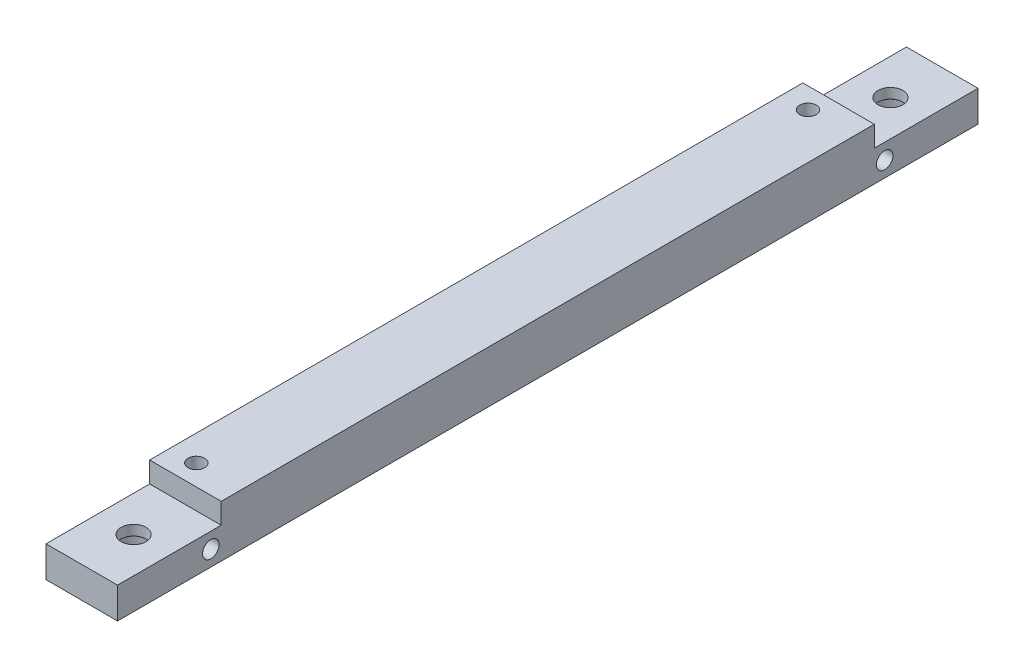
from build123d import *

# Parameters (mm, degrees)
SKETCH1_W                                      = 83
SKETCH1_H                                      = 6
BOSS_EXTRUDE1_DEPTH                            = 8.5
SKETCH7_W                                      = 8.5
SKETCH7_H                                      = 10
CUT_EXTRUDE6_DEPTH                             = 3
SKETCH18_W                                     = 10
SKETCH18_H                                     = 3
CUT_EXTRUDE8_DEPTH                             = 10
SKETCH21_W                                     = 63
SKETCH21_H                                     = 1
CUT_EXTRUDE9_DEPTH                             = 10
M2X0_4_TAPPED_HOLE3_D                          = 1.6
SKETCH27_W                                     = 1.6
SKETCH27_H                                     = 83
CUT_EXTRUDE12_DEPTH                            = 10
CBORE_FOR_M2_SOCKET_HEAD_CAP_SCREW1_AT_2_COUNT = 2
CBORE_FOR_M2_SOCKET_HEAD_CAP_SCREW1_AT_2_PITCH = 73
M2X0_4_TAPPED_HOLE2_D                          = 1.6


with BuildPart() as part:
    # Sketch1 → Boss-Extrude1 (new body)
    with BuildSketch(Plane(origin=(0, 0, 0), x_dir=(0, 0, -1), z_dir=(1, 0, 0))):
        with Locations((41.5, -5.098419508)):
            Rectangle(SKETCH1_W, SKETCH1_H)
    extrude(amount=BOSS_EXTRUDE1_DEPTH)

    # Sketch7 → Cut-Extrude6 (cut)
    with BuildSketch(Plane(origin=(0, -2.098419508, 0), x_dir=(1, 0, 0), z_dir=(0, 1, 0))):
        with Locations((4.25, 5)):
            Rectangle(SKETCH7_W, SKETCH7_H)
    extrude(amount=-CUT_EXTRUDE6_DEPTH, mode=Mode.SUBTRACT)

    # Sketch18 → Cut-Extrude8 (cut)
    with BuildSketch(Plane(origin=(8.5, 0, 0), x_dir=(0, 0, -1), z_dir=(1, 0, 0))):
        with Locations((78, -3.598419508)):
            Rectangle(SKETCH18_W, SKETCH18_H)
    extrude(amount=-CUT_EXTRUDE8_DEPTH, mode=Mode.SUBTRACT)

    # Sketch21 → Cut-Extrude9 (cut)
    with BuildSketch(Plane.ZY):
        with Locations((-41.5, -2.598419508)):
            Rectangle(SKETCH21_W, SKETCH21_H)
    extrude(amount=-CUT_EXTRUDE9_DEPTH, mode=Mode.SUBTRACT)

    # M2x0.4 Tapped Hole3 (through all)
    with Locations(Plane.ZY):
        with Locations((-74, -6.598419508), (-9, -6.598419508)):
            Hole(M2X0_4_TAPPED_HOLE3_D / 2)

    # Sketch27 → Cut-Extrude12 (cut)
    with BuildSketch(Plane.XZ.offset(8.098419508)):
        with Locations((0.8, -41.5)):
            Rectangle(SKETCH27_W, SKETCH27_H)
    extrude(amount=-CUT_EXTRUDE12_DEPTH, mode=Mode.SUBTRACT)

    # Sketch31 → CBORE for M2 Socket Head Cap Screw1 (revolve, cut)
    with BuildSketch(Plane(origin=(5.05, -8.098419508, -5), x_dir=(0, 0, -1), z_dir=(1, 0, 0))):
        Polygon((0, 0), (0, 5), (1.2, 5), (1.2, 2.025), (1.225, 2), (2.2, 2), (2.2, 0), align=None)
    cbore_for_m2_socket_head_cap_screw1 = revolve(axis=Axis((5.05, -14.448419508, -5), (0, 1, 0)), mode=Mode.SUBTRACT)

    # CBORE for M2 Socket Head Cap Screw1 at 2: CBORE for M2 Socket Head Cap Screw1 ×2
    with Locations(*[(0, 0, -i * CBORE_FOR_M2_SOCKET_HEAD_CAP_SCREW1_AT_2_PITCH) for i in range(1, CBORE_FOR_M2_SOCKET_HEAD_CAP_SCREW1_AT_2_COUNT)]):
        add(cbore_for_m2_socket_head_cap_screw1, mode=Mode.SUBTRACT)

    # M2x0.4 Tapped Hole2 (through all)
    with Locations(Plane(origin=(0, -8.098419508, 0), x_dir=(-1, 0, 0), z_dir=(0, -1, 0))):
        with Locations((-4.1, 71), (-4.1, 12)):
            Hole(M2X0_4_TAPPED_HOLE2_D / 2)


solid = part.part
